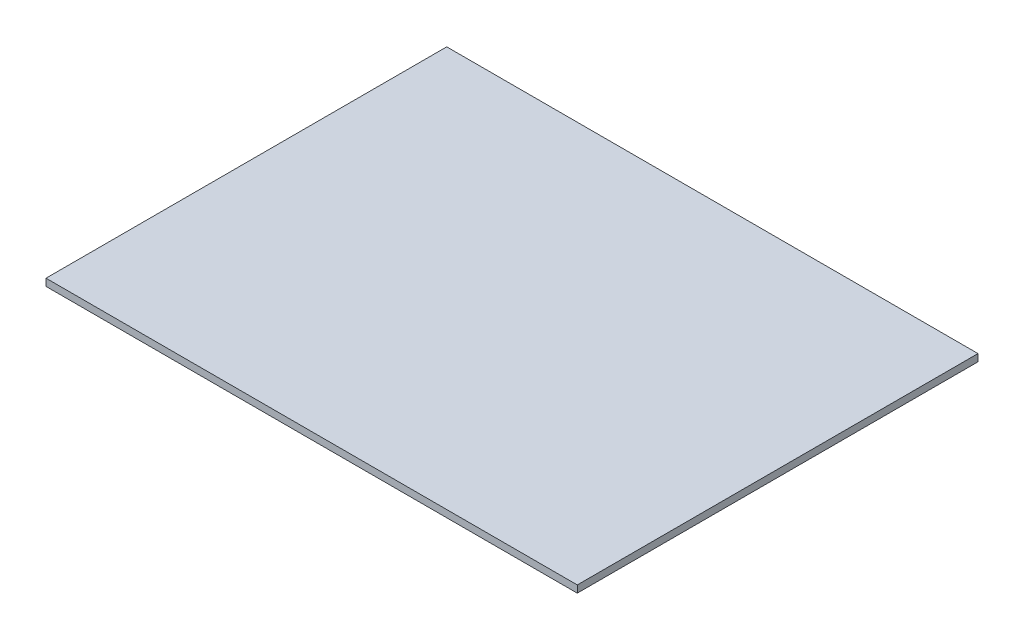
from build123d import *

# Parameters (mm, degrees)
SKETCH1_W           = 446
SKETCH1_H           = 336.4
BOSS_EXTRUDE1_DEPTH = 6


with BuildPart() as part:
    # Sketch1 → Boss-Extrude1 (new body)
    with BuildSketch(Plane(origin=(0, 0, 0), x_dir=(1, 0, 0), z_dir=(0, 1, 0))):
        with Locations((223, 168.2)):
            Rectangle(SKETCH1_W, SKETCH1_H)
    extrude(amount=BOSS_EXTRUDE1_DEPTH)


solid = part.part
